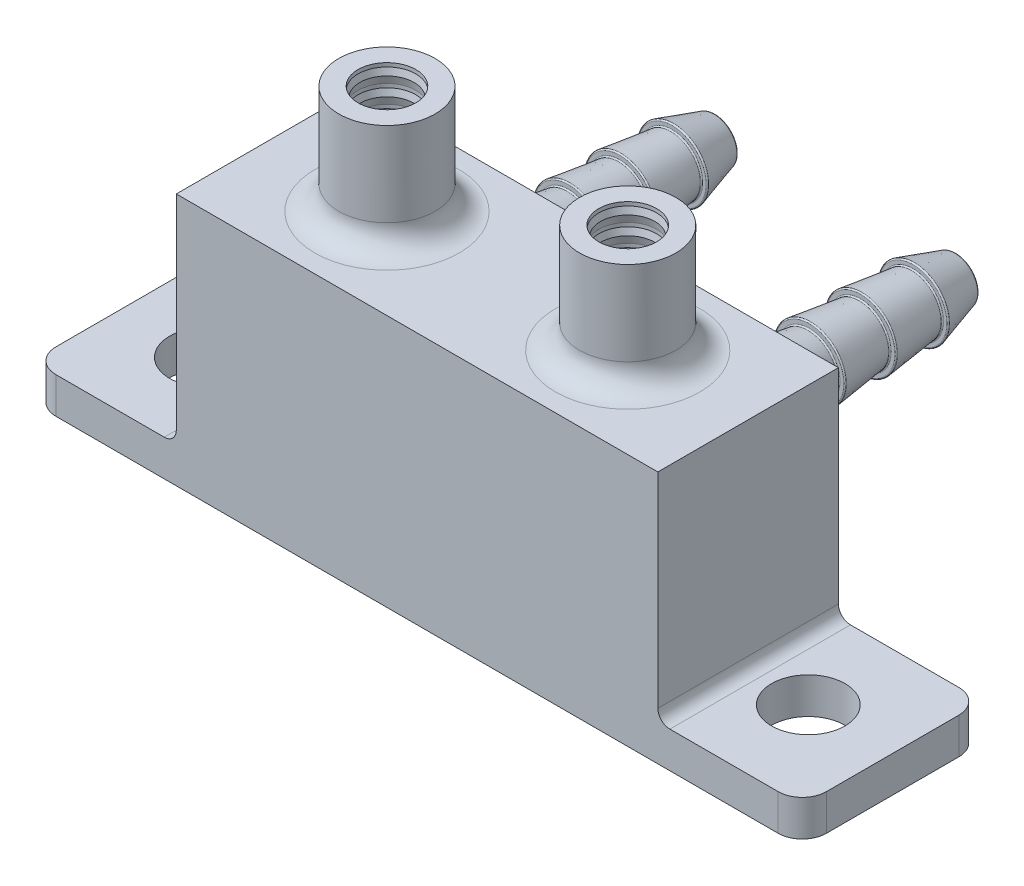
from build123d import *

# Parameters (mm, degrees)
SKETCH1_W            = 40
SKETCH1_H            = 15
BOSS_EXTRUDE1_DEPTH  = 15
SKETCH2_W            = 40
SKETCH2_H            = 15
BOSS_EXTRUDE2_DEPTH  = 3
SKETCH5_R            = 3.05
BOSS_EXTRUDE3_DEPTH  = 3
FILLET1_R            = 2
FILLET2_R            = 1
CUT_EXTRUDE1_START   = -2.669873
SKETCH59_R           = 2.5
CUT_EXTRUDE1_DEPTH   = 2.669873
CUT_EXTRUDE3_START   = -3.5
SKETCH62_R           = 1.5
CUT_EXTRUDE3_DEPTH   = 3.5
FILLET5_R            = 2
FILLET1_OF_MIRROR1_R = 2
FILLET5_OF_MIRROR1_R = 2


with BuildPart() as part:
    # Sketch1 → Boss-Extrude1 (new body)
    with BuildSketch(Plane(origin=(0, 0, 0), x_dir=(1, 0, 0), z_dir=(0, 1, 0))):
        Rectangle(SKETCH1_W, SKETCH1_H)
    extrude(amount=BOSS_EXTRUDE1_DEPTH)

    # Sketch2 → Boss-Extrude2 (add)
    with BuildSketch(Plane(origin=(0, 15, 0), x_dir=(1, 0, 0), z_dir=(0, 1, 0))):
        Rectangle(SKETCH2_W, SKETCH2_H)
    extrude(amount=BOSS_EXTRUDE2_DEPTH)

    # Sketch4 → Revolve1 (revolve)
    with BuildSketch(Plane.XY):
        Polygon((12.4, 27), (12.4, 26.687093665), (12.25, 26.145831823), (12.4, 25.5), (12.4, 25.187093665), (12.25, 24.645831823), (12.4, 24), (12.4, 23.687093665), (12.25, 23.145831823), (12.4, 22.5), (12.4, 22.187093665), (12.25, 21.645831823), (12.4, 21), (12.4, 20.687093665), (12.25, 20.145831823), (12.4, 19.5), (12.4, 19.187093665), (12.25, 18.645831823), (12.4, 18), (12.4, 17.687093665), (12.25, 17.145831823), (12.4, 16.5), (12.4, 16.187093665), (12.25, 15.645831823), (12.4, 15), (14, 15), (14, 27), align=None)
    revolve1 = revolve(axis=Axis((10, 0, 0), (0, 1, 0)))

    # Sketch5 → Boss-Extrude3 (add)
    with BuildSketch(Plane.XZ):
        with BuildLine():
            Line((30, -7.5), (-30, -7.5))
            ThreePointArc((-30, -7.5), (-31.414213562, -6.914213562), (-32, -5.5))
            Line((-32, -5.5), (-32, 5.5))
            ThreePointArc((-32, 5.5), (-31.414213562, 6.914213562), (-30, 7.5))
            Line((-30, 7.5), (30, 7.5))
            ThreePointArc((30, 7.5), (31.414213562, 6.914213562), (32, 5.5))
            Line((32, 5.5), (32, -5.5))
            ThreePointArc((32, -5.5), (31.414213562, -6.914213562), (30, -7.5))
        make_face()
        with Locations((25, 0)):
            Circle(SKETCH5_R, mode=Mode.SUBTRACT)
        with Locations((-25, 0)):
            Circle(SKETCH5_R, mode=Mode.SUBTRACT)
    extrude(amount=BOSS_EXTRUDE3_DEPTH)

    # Fillet1
    fillet1_edges = [part.edges().sort_by_distance(p)[0] for p in [
        (6, 18, 0),
    ]]
    fillet(fillet1_edges, radius=FILLET1_R)

    # Fillet2
    fillet2_edges = [part.edges().sort_by_distance(p)[0] for p in [
        (20, 0, 0),
        (-20, 0, 0),
    ]]
    fillet(fillet2_edges, radius=FILLET2_R)

    # Sketch56 → Cut-Revolve1 (revolve, cut)
    with BuildSketch(Plane.XY):
        with BuildLine():
            Line((10, 16), (10, 6))
            ThreePointArc((10, 6), (15, 11), (10, 16))
        make_face()
    cut_revolve1 = revolve(axis=Axis((10, 16, 0), (0, -1, 0)), mode=Mode.SUBTRACT)

    # Sketch59 → Cut-Extrude1 (cut)
    with BuildSketch(Plane(origin=(0, 18, 0), x_dir=(1, 0, 0), z_dir=(0, 1, 0)).offset(CUT_EXTRUDE1_START)):
        with Locations((10, 0)):
            Circle(SKETCH59_R)
    cut_extrude1 = extrude(amount=CUT_EXTRUDE1_DEPTH, mode=Mode.SUBTRACT)

    # Sketch61 → Revolve2 (revolve)
    with BuildSketch(Plane(origin=(10, 0, 0), x_dir=(0, 0, -1), z_dir=(1, 0, 0))):
        with BuildLine():
            Line((27.144178344, 11.418911495), (23.811965275, 12.422402649))
            ThreePointArc((23.811965275, 12.422402649), (23.723478818, 12.406911064), (23.683129606, 12.326650342))
            Line((23.683129606, 12.326650342), (23.683129606, 12.053108496))
            ThreePointArc((23.683129606, 12.053108496), (23.649384164, 11.978206336), (23.570922935, 11.953856306))
            Line((23.570922935, 11.953856306), (19.445453696, 12.461232985))
            ThreePointArc((19.445453696, 12.461232985), (19.366992467, 12.436882956), (19.333247024, 12.361980796))
            Line((19.333247024, 12.361980796), (19.333247024, 12.05376017))
            ThreePointArc((19.333247024, 12.05376017), (19.299287737, 11.978669396), (19.220474539, 11.954579206))
            Line((19.220474539, 11.954579206), (15.186647669, 12.474053841))
            ThreePointArc((15.186647669, 12.474053841), (15.107834471, 12.449963651), (15.073875184, 12.374872877))
            Line((15.073875184, 12.374872877), (15.073875184, 12.056850119))
            ThreePointArc((15.073875184, 12.056850119), (15.038913485, 11.980889475), (14.958474795, 11.958043095))
            Line((14.958474795, 11.958043095), (11.481345181, 12.5))
            Line((11.481345181, 12.5), (7.5, 12.5))
            Line((7.5, 12.5), (7.5, 11))
            Line((7.5, 11), (27.086507007, 11))
            ThreePointArc((27.086507007, 11), (27.227928363, 11.058578644), (27.286507007, 11.2))
            Line((27.286507007, 11.2), (27.286507007, 11.227406882))
            ThreePointArc((27.286507007, 11.227406882), (27.24702845, 11.346708459), (27.144178344, 11.418911495))
        make_face()
    revolve2 = revolve(axis=Axis((10, 9.5, -7.5), (0, 0, -1)))

    # Sketch62 → Cut-Extrude3 (cut)
    with BuildSketch(Plane(origin=(0, 0, -7.5), x_dir=(-1, 0, 0), z_dir=(0, 0, -1)).offset(CUT_EXTRUDE3_START)):
        with Locations((-10, 9.5)):
            Circle(SKETCH62_R)
    cut_extrude3 = extrude(amount=CUT_EXTRUDE3_DEPTH, mode=Mode.SUBTRACT)

    # Fillet5
    fillet5_edges = [part.edges().sort_by_distance(p)[0] for p in [
        (10, 6.5, -7.5),
    ]]
    fillet(fillet5_edges, radius=FILLET5_R)

    # Mirror1: Revolve1, Cut-Revolve1, Cut-Extrude1, Revolve2, Cut-Extrude3 across plane
    add(revolve1.mirror(Plane(origin=(0, 0, 0), x_dir=(0, 0, 1), z_dir=(1, 0, 0))))
    add(cut_revolve1.mirror(Plane(origin=(0, 0, 0), x_dir=(0, 0, 1), z_dir=(1, 0, 0))), mode=Mode.SUBTRACT)
    add(cut_extrude1.mirror(Plane(origin=(0, 0, 0), x_dir=(0, 0, 1), z_dir=(1, 0, 0))), mode=Mode.SUBTRACT)
    add(revolve2.mirror(Plane(origin=(0, 0, 0), x_dir=(0, 0, 1), z_dir=(1, 0, 0))))
    add(cut_extrude3.mirror(Plane(origin=(0, 0, 0), x_dir=(0, 0, 1), z_dir=(1, 0, 0))), mode=Mode.SUBTRACT)

    # Fillet1 of Mirror1
    fillet1_of_mirror1_edges = [part.edges().sort_by_distance(p)[0] for p in [
        (-6, 18, 0),
    ]]
    fillet(fillet1_of_mirror1_edges, radius=FILLET1_OF_MIRROR1_R)

    # Fillet5 of Mirror1
    fillet5_of_mirror1_edges = [part.edges().sort_by_distance(p)[0] for p in [
        (-10, 6.5, -7.5),
    ]]
    fillet(fillet5_of_mirror1_edges, radius=FILLET5_OF_MIRROR1_R)


solid = part.part
